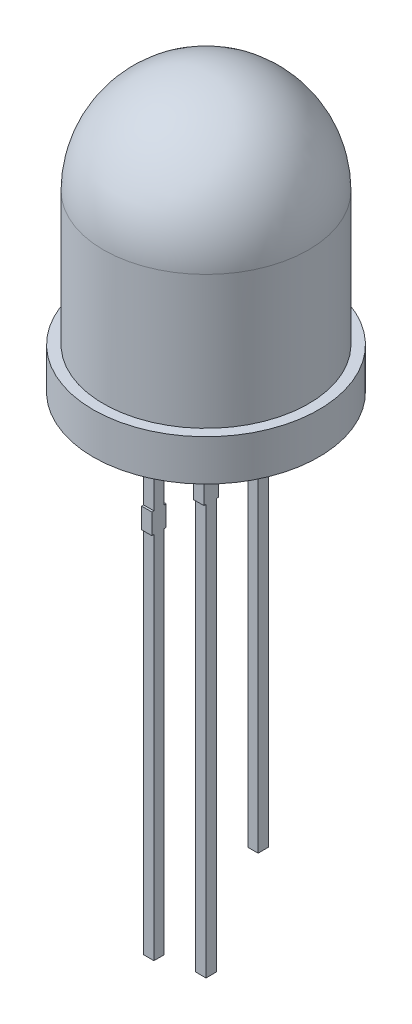
from build123d import *

# Parameters (mm, degrees)
SKETCH2_R          = 5.5
EXTRUDE1_DEPTH     = 2
SKETCH3_W          = 0.5
SKETCH3_H          = 16
SKETCH3_H_2        = 1
SKETCH3_W_2        = 0.1
SKETCH3_H_3        = 24.5
SKETCH3_W_3        = 0.7
EXTRUDE2_DEPTH     = 0.25
SKETCH4_W          = 0.026582279
SKETCH4_H          = 0.025316456
CUT_EXTRUDE1_DEPTH = 0.01


with BuildPart() as part:
    # Sketch1 → Revolve1 (revolve)
    with BuildSketch(Plane.XY):
        with BuildLine():
            ThreePointArc((0, 11.5), (3.535533906, 10.035533906), (5, 6.5))
            Line((5, 6.5), (5, 0))
            Line((5, 0), (0, 0))
            Line((0, 0), (0, 11.5))
        make_face()
    revolve(axis=Axis((0, 0, 0), (0, 1, 0)))

    # Sketch2 → Extrude1 (add)
    with BuildSketch(Plane.XZ.offset(2)):
        with Locations(Location((0, 0, 0), (0, 0, 270))):  # turned: the seam where the file's is
            Circle(SKETCH2_R)
    extrude(amount=-EXTRUDE1_DEPTH)

    # Sketch3 → Extrude2 (add, symmetric)
    with BuildSketch(Plane(origin=(0, 0, 0), x_dir=(0, 0, -1), z_dir=(1, 0, 0))):
        with Locations((2.54, -14.5)):
            Rectangle(SKETCH3_W, SKETCH3_H)
        Polygon((2.79, -3.5), (1.992435853, -2), (1.492435853, -2), (2.29, -3.5), (2.29, -5.5), (2.79, -5.5), align=None)
        with Locations((2.54, -6)):
            Rectangle(SKETCH3_W, SKETCH3_H_2)
        with Locations((2.24, -6)):
            Rectangle(SKETCH3_W_2, SKETCH3_H_2)
        with Locations((2.84, -6)):
            Rectangle(SKETCH3_W_2, SKETCH3_H_2)
        with Locations((0, -14.25)):
            Rectangle(SKETCH3_W, SKETCH3_H_3)
        with Locations((0, -6)):
            Rectangle(SKETCH3_W_3, SKETCH3_H_2)
        with Locations((-2.54, -6)):
            Rectangle(SKETCH3_W_3, SKETCH3_H_2)
        Polygon((-2.29, -24.5), (-2.29, -3.5), (-1.29, -3.5), (-1.29, -2), (-1.79, -2), (-1.79, -3), (-2.79, -3), (-2.79, -24.5), align=None)
    extrude(amount=EXTRUDE2_DEPTH, both=True)

    # Sketch4 → Cut-Extrude1 (cut)
    with BuildSketch(Plane.XZ.offset(2)):
        Polygon((-3.369199885, 0.572151899), (-3.44388343, 0.595609177), (-3.44388343, 0.620352057), (-3.393547196, 0.636768196), (-3.44388343, 0.652294304), (-3.44388343, 0.678026108), (-3.369199885, 0.701265823), (-3.369199885, 0.676087816), (-3.420683272, 0.663093354), (-3.369199885, 0.646677215), (-3.369199885, 0.625178006), (-3.420683272, 0.608860759), (-3.369199885, 0.596044304), align=None)
        Polygon((-3.369199885, 0.437974684), (-3.44388343, 0.461431962), (-3.44388343, 0.486174842), (-3.393547196, 0.502590981), (-3.44388343, 0.518117089), (-3.44388343, 0.543848892), (-3.369199885, 0.567088608), (-3.369199885, 0.541910601), (-3.420683272, 0.528916139), (-3.369199885, 0.5125), (-3.369199885, 0.491000791), (-3.420683272, 0.474683544), (-3.369199885, 0.461867089), align=None)
        Polygon((-3.369199885, 0.303797468), (-3.44388343, 0.327254747), (-3.44388343, 0.351997627), (-3.393547196, 0.368413766), (-3.44388343, 0.383939873), (-3.44388343, 0.409671677), (-3.369199885, 0.432911392), (-3.369199885, 0.407733386), (-3.420683272, 0.394738924), (-3.369199885, 0.378322785), (-3.369199885, 0.356823576), (-3.420683272, 0.340506329), (-3.369199885, 0.327689873), align=None)
        with Locations((-3.43059229, 0.275949367)):
            Rectangle(SKETCH4_W, SKETCH4_H)
        with BuildLine():
            add(Edge.make_bspline(
                [(-3.412712544, 0.159493671), (-3.413934677, 0.159530169), (-3.41633454, 0.15960184), (-3.419842228, 0.160211426), (-3.423166531, 0.161205393), (-3.426330677, 0.162577732), (-3.429300166, 0.164371189), (-3.432103057, 0.16655446), (-3.434707602, 0.169143343), (-3.437143976, 0.172090146), (-3.439326088, 0.175387089), (-3.441232121, 0.178984804), (-3.442826792, 0.18286483), (-3.444165857, 0.187013042), (-3.445154291, 0.191459588), (-3.445878278, 0.196177087), (-3.446351596, 0.201170514), (-3.446393564, 0.204594091), (-3.446415075, 0.206348892)],
                knots=[0, 0, 0, 0, 0.907312236, 1.78165839, 2.635367075, 3.479697475, 4.336364812, 5.205276731, 6.11257575, 7.058770404, 8.040786331, 9.044147278, 10.078219212, 11.153049307, 12.278104542, 13.457648573, 14.696882856, 16, 16, 16, 16], degree=3))
            add(Edge.make_bspline(
                [(-3.446415075, 0.206348892), (-3.446391004, 0.208367148), (-3.446344379, 0.21227633), (-3.44591578, 0.217939855), (-3.44526964, 0.223207892), (-3.444303099, 0.228103607), (-3.443102333, 0.232708206), (-3.441811042, 0.237141474), (-3.440346626, 0.241422786), (-3.439246468, 0.244195876), (-3.438701468, 0.24556962)],
                knots=[0, 0, 0, 0, 1.203215828, 2.33052265, 3.384689099, 4.366106119, 5.303329643, 6.221311756, 7.118865988, 8, 8, 8, 8], degree=3))
            Line((-3.438701468, 0.24556962), (-3.414769506, 0.24556962))
            Line((-3.414769506, 0.24556962), (-3.414769506, 0.242721519))
            add(Edge.make_bspline(
                [(-3.414769506, 0.242721519), (-3.415850961, 0.241356205), (-3.418007522, 0.238633592), (-3.420770127, 0.234200359), (-3.42317229, 0.229552713), (-3.425146291, 0.224707243), (-3.426732616, 0.219810398), (-3.427826143, 0.21493502), (-3.428573492, 0.210169433), (-3.428653998, 0.207010864), (-3.428693556, 0.205458861)],
                knots=[0, 0, 0, 0, 1.030622468, 2.055194264, 3.087043286, 4.125157485, 5.149848264, 6.130935704, 7.081611712, 8, 8, 8, 8], degree=3))
            add(Edge.make_bspline(
                [(-3.428693556, 0.205458861), (-3.428692662, 0.205030082), (-3.428690747, 0.2041121), (-3.428561904, 0.202644063), (-3.42846874, 0.200985464), (-3.428259523, 0.199206598), (-3.42804094, 0.197415781), (-3.427660619, 0.195761121), (-3.427298781, 0.194257482), (-3.426930603, 0.193351), (-3.426755265, 0.192919304)],
                knots=[0, 0, 0, 0, 0.806378557, 1.726393851, 2.771014456, 3.931269413, 5.096090628, 6.161710732, 7.124547685, 8, 8, 8, 8], degree=3))
            add(Edge.make_bspline(
                [(-3.426755265, 0.192919304), (-3.426527441, 0.192439517), (-3.426079719, 0.191496634), (-3.425262113, 0.190201714), (-3.424390811, 0.189019042), (-3.423425392, 0.187957582), (-3.422247483, 0.187107314), (-3.420846627, 0.186479113), (-3.419196327, 0.186136019), (-3.418021316, 0.186096725), (-3.417400044, 0.186075949)],
                knots=[0, 0, 0, 0, 1.024407818, 2.013179384, 2.949802342, 3.859052226, 4.77034807, 5.732977883, 6.801339628, 8, 8, 8, 8], degree=3))
            add(Edge.make_bspline(
                [(-3.417400044, 0.186075949), (-3.416854148, 0.186107391), (-3.415780755, 0.186169215), (-3.414252759, 0.186751006), (-3.412830882, 0.187633905), (-3.411570167, 0.188920927), (-3.410412728, 0.190515003), (-3.409442431, 0.19247074), (-3.408562358, 0.194723719), (-3.408145089, 0.196368178), (-3.407926151, 0.197231013)],
                knots=[0, 0, 0, 0, 0.825212765, 1.622611382, 2.449701629, 3.348069183, 4.336544339, 5.428209675, 6.6506027, 8, 8, 8, 8], degree=3))
            add(Edge.make_bspline(
                [(-3.407926151, 0.197231013), (-3.407478411, 0.19919974), (-3.406561221, 0.203232648), (-3.405414114, 0.209380757), (-3.404148041, 0.215510984), (-3.4029385, 0.219469696), (-3.40234862, 0.221400316)],
                knots=[0, 0, 0, 0, 0.976104583, 1.999535498, 3.024395274, 4, 4, 4, 4], degree=3))
            add(Edge.make_bspline(
                [(-3.40234862, 0.221400316), (-3.401995627, 0.222438832), (-3.401308494, 0.224460401), (-3.400146869, 0.227351945), (-3.398876917, 0.230013057), (-3.397521785, 0.232453168), (-3.396047787, 0.23465249), (-3.394514398, 0.236647679), (-3.392860561, 0.238391205), (-3.391128641, 0.239938889), (-3.389276638, 0.241262203), (-3.387332502, 0.242416954), (-3.385272036, 0.243392589), (-3.383110748, 0.244201473), (-3.380831879, 0.244818545), (-3.378455006, 0.245239801), (-3.375971646, 0.24553819), (-3.374277292, 0.245559001), (-3.373412702, 0.24556962)],
                knots=[0, 0, 0, 0, 1.287286806, 2.505824366, 3.654938963, 4.74627059, 5.778586806, 6.75996495, 7.696030012, 8.595059759, 9.482019644, 10.363222407, 11.245851011, 12.154256429, 13.068444161, 14.012503255, 14.985824751, 16, 16, 16, 16], degree=3))
            add(Edge.make_bspline(
                [(-3.373412702, 0.24556962), (-3.372256557, 0.245532318), (-3.369981285, 0.245458909), (-3.366652241, 0.24485748), (-3.363503504, 0.24383089), (-3.360500041, 0.242444827), (-3.357686955, 0.240616199), (-3.355008407, 0.238431404), (-3.352536816, 0.235807357), (-3.350236482, 0.232830235), (-3.348157084, 0.229542851), (-3.346326527, 0.226003867), (-3.344789876, 0.222234578), (-3.343515982, 0.218249032), (-3.342561311, 0.214030563), (-3.341842379, 0.20959333), (-3.341429198, 0.204919541), (-3.341377947, 0.20172812), (-3.341351784, 0.200098892)],
                knots=[0, 0, 0, 0, 0.894990994, 1.761326291, 2.609044902, 3.454222546, 4.315366365, 5.200560057, 6.125081389, 7.100429509, 8.110379559, 9.133447974, 10.182136699, 11.259192205, 12.370181258, 13.528580438, 14.738335141, 16, 16, 16, 16], degree=3))
            add(Edge.make_bspline(
                [(-3.341351784, 0.200098892), (-3.341373976, 0.198430205), (-3.341418321, 0.19509566), (-3.341796299, 0.190114218), (-3.342351527, 0.185153716), (-3.343193232, 0.180289886), (-3.344169649, 0.175599331), (-3.345265445, 0.171186095), (-3.346503409, 0.167106634), (-3.347457754, 0.16453297), (-3.34791824, 0.163291139)],
                knots=[0, 0, 0, 0, 1.065403572, 2.129000689, 3.188532477, 4.251604565, 5.279552602, 6.247508681, 7.154397237, 8, 8, 8, 8], degree=3))
            Line((-3.34791824, 0.163291139), (-3.370465708, 0.163291139))
            Line((-3.370465708, 0.163291139), (-3.370465708, 0.166119462))
            add(Edge.make_bspline(
                [(-3.370465708, 0.166119462), (-3.369665362, 0.167192367), (-3.368028632, 0.169386485), (-3.365944959, 0.173046122), (-3.363987094, 0.177004358), (-3.362302935, 0.181283188), (-3.360843454, 0.185742216), (-3.359824288, 0.190325174), (-3.359182478, 0.194951338), (-3.359109703, 0.198053049), (-3.359073303, 0.19960443)],
                knots=[0, 0, 0, 0, 0.892283326, 1.824742884, 2.804416662, 3.836872171, 4.8899239, 5.931447339, 6.965372909, 8, 8, 8, 8], degree=3))
            add(Edge.make_bspline(
                [(-3.359073303, 0.19960443), (-3.359094755, 0.200700098), (-3.359137658, 0.202891315), (-3.359528342, 0.206159523), (-3.360159236, 0.209401584), (-3.360978517, 0.211442107), (-3.361387385, 0.212460443)],
                knots=[0, 0, 0, 0, 0.999146175, 1.998183711, 3.000980573, 4, 4, 4, 4], degree=3))
            add(Edge.make_bspline(
                [(-3.361387385, 0.212460443), (-3.361588852, 0.212893946), (-3.361991651, 0.213760664), (-3.362764215, 0.214967308), (-3.363693026, 0.216071977), (-3.364745019, 0.217064055), (-3.365901392, 0.217932452), (-3.367176218, 0.218547803), (-3.368539133, 0.218923676), (-3.369474364, 0.218965835), (-3.369951468, 0.218987342)],
                knots=[0, 0, 0, 0, 1.00524851, 2.009826503, 3.004679593, 4.035271301, 5.048246368, 6.034938417, 6.997532266, 8, 8, 8, 8], degree=3))
            add(Edge.make_bspline(
                [(-3.369951468, 0.218987342), (-3.370589633, 0.218952904), (-3.371809109, 0.218887095), (-3.373524905, 0.218280511), (-3.375003339, 0.217295678), (-3.375998259, 0.216135073), (-3.376695697, 0.215017943), (-3.377206207, 0.213982284), (-3.377689566, 0.212773057), (-3.378187034, 0.211401809), (-3.378678222, 0.209865482), (-3.379153769, 0.208156925), (-3.379603064, 0.206274208), (-3.379889255, 0.204958333), (-3.380038493, 0.204272152)],
                knots=[0, 0, 0, 0, 1.173816843, 2.243057204, 3.312297565, 4.415174738, 5.03266065, 5.73970059, 6.541434878, 7.433956553, 8.430083051, 9.515931566, 10.70464786, 12, 12, 12, 12], degree=3))
            add(Edge.make_bspline(
                [(-3.380038493, 0.204272152), (-3.380414555, 0.202439363), (-3.381153432, 0.198838337), (-3.382256921, 0.193437153), (-3.38353189, 0.18793438), (-3.384680693, 0.184269053), (-3.38527979, 0.182357595)],
                knots=[0, 0, 0, 0, 0.995744513, 1.956417928, 2.934277412, 4, 4, 4, 4], degree=3))
            add(Edge.make_bspline(
                [(-3.38527979, 0.182357595), (-3.385599034, 0.181411041), (-3.386223527, 0.179559428), (-3.38730981, 0.176918797), (-3.388483792, 0.174471738), (-3.389725324, 0.172204706), (-3.39106929, 0.170130736), (-3.392491937, 0.168236053), (-3.394018846, 0.166552235), (-3.395632073, 0.16505467), (-3.397342174, 0.16373551), (-3.399181246, 0.162603212), (-3.401130049, 0.161630984), (-3.403216249, 0.160861379), (-3.405410836, 0.160243358), (-3.407742203, 0.159820261), (-3.41018658, 0.159526278), (-3.411861157, 0.159504661), (-3.412712544, 0.159493671)],
                knots=[0, 0, 0, 0, 1.237467875, 2.420686895, 3.535046182, 4.599015201, 5.620884487, 6.594603852, 7.531477383, 8.433220087, 9.318759595, 10.202828513, 11.105163009, 12.01247538, 12.953896178, 13.926381251, 14.945733412, 16, 16, 16, 16], degree=3))
        make_face()
        with BuildLine():
            Line((-3.44388343, 0.067088608), (-3.44388343, 0.091139241))
            Line((-3.44388343, 0.091139241), (-3.436051151, 0.091139241))
            add(Edge.make_bspline(
                [(-3.436051151, 0.091139241), (-3.43685971, 0.092232549), (-3.438418598, 0.094340433), (-3.440498816, 0.097513458), (-3.442274082, 0.100539548), (-3.443833302, 0.103453039), (-3.445008688, 0.106475242), (-3.445836754, 0.109706756), (-3.446336527, 0.113209581), (-3.446388311, 0.115636475), (-3.446415075, 0.116890823)],
                knots=[0, 0, 0, 0, 1.150872466, 2.218865267, 3.209461834, 4.120482262, 5.012764827, 5.946708227, 6.938749913, 8, 8, 8, 8], degree=3))
            add(Edge.make_bspline(
                [(-3.446415075, 0.116890823), (-3.446392356, 0.117907175), (-3.446348116, 0.119886305), (-3.446003238, 0.122763545), (-3.445465587, 0.125471173), (-3.444657996, 0.127986213), (-3.443692193, 0.130350202), (-3.442412235, 0.132487752), (-3.44098206, 0.134491354), (-3.439275015, 0.136273026), (-3.437377282, 0.137888648), (-3.435244821, 0.139271198), (-3.432911896, 0.140448909), (-3.430360042, 0.141390006), (-3.427601739, 0.142145096), (-3.424622491, 0.142669028), (-3.421435363, 0.142989621), (-3.419240233, 0.14302156), (-3.418112069, 0.143037975)],
                knots=[0, 0, 0, 0, 1.109008058, 2.159558935, 3.158726032, 4.116861086, 5.039058877, 5.938775559, 6.82970133, 7.720510853, 8.624361809, 9.544451588, 10.487360536, 11.471068125, 12.508000841, 13.604731202, 14.768976642, 16, 16, 16, 16], degree=3))
            Line((-3.418112069, 0.143037975), (-3.369199885, 0.143037975))
            Line((-3.369199885, 0.143037975), (-3.369199885, 0.118987342))
            Line((-3.369199885, 0.118987342), (-3.406778999, 0.118987342))
            add(Edge.make_bspline(
                [(-3.406778999, 0.118987342), (-3.40769547, 0.118985706), (-3.409449686, 0.118982576), (-3.411955492, 0.118900237), (-3.414223665, 0.118779336), (-3.416265694, 0.118640631), (-3.418112444, 0.118387615), (-3.419778606, 0.118009906), (-3.421298207, 0.11753908), (-3.422204909, 0.117074761), (-3.422641341, 0.116851266)],
                knots=[0, 0, 0, 0, 1.361401701, 2.605856924, 3.723918663, 4.735739235, 5.645738665, 6.489217889, 7.27279937, 8, 8, 8, 8], degree=3))
            add(Edge.make_bspline(
                [(-3.422641341, 0.116851266), (-3.423040056, 0.116621259), (-3.423823895, 0.116169086), (-3.424830074, 0.115248796), (-3.425674341, 0.114170053), (-3.42633037, 0.112892449), (-3.426829318, 0.111405901), (-3.427169555, 0.109677971), (-3.427385057, 0.107692609), (-3.427412965, 0.106283591), (-3.427427734, 0.105537975)],
                knots=[0, 0, 0, 0, 0.849138082, 1.669332372, 2.503455908, 3.370611167, 4.311442699, 5.394692208, 6.621337967, 8, 8, 8, 8], degree=3))
            add(Edge.make_bspline(
                [(-3.427427734, 0.105537975), (-3.427410376, 0.104996691), (-3.427374689, 0.103883773), (-3.427142243, 0.102172461), (-3.426785568, 0.100375884), (-3.426125713, 0.097861301), (-3.424939534, 0.094694674), (-3.423585126, 0.092335372), (-3.422898461, 0.091139241)],
                knots=[0, 0, 0, 0, 0.638127216, 1.312033637, 2.033062677, 2.79661882, 4.375931797, 6, 6, 6, 6], degree=3))
            Line((-3.422898461, 0.091139241), (-3.369199885, 0.091139241))
            Line((-3.369199885, 0.091139241), (-3.369199885, 0.067088608))
            Line((-3.369199885, 0.067088608), (-3.44388343, 0.067088608))
        make_face()
        with BuildLine():
            Line((-3.44388343, -0.030379747), (-3.44388343, -0.006329114))
            Line((-3.44388343, -0.006329114), (-3.406304316, -0.006329114))
            add(Edge.make_bspline(
                [(-3.406304316, -0.006329114), (-3.404774273, -0.0063046), (-3.401723248, -0.006255716), (-3.397960837, -0.005973592), (-3.395118513, -0.00559507), (-3.393280632, -0.005225415), (-3.391732492, -0.004793715), (-3.390846733, -0.004381435), (-3.390441974, -0.004193038)],
                knots=[0, 0, 0, 0, 1.709124929, 3.408128882, 4.211124727, 4.91016634, 5.501986363, 6, 6, 6, 6], degree=3))
            add(Edge.make_bspline(
                [(-3.390441974, -0.004193038), (-3.390043921, -0.003948575), (-3.389263481, -0.003469272), (-3.388250468, -0.002531948), (-3.387421627, -0.001438061), (-3.386740076, -0.000167292), (-3.386269496, 0.001323905), (-3.385876266, 0.003040645), (-3.385709357, 0.005027263), (-3.385674197, 0.006434533), (-3.385655582, 0.007179589)],
                knots=[0, 0, 0, 0, 0.86006424, 1.686277094, 2.52783008, 3.38194165, 4.331801563, 5.402842185, 6.624978739, 8, 8, 8, 8], degree=3))
            add(Edge.make_bspline(
                [(-3.385655582, 0.007179589), (-3.385712319, 0.00831141), (-3.385828172, 0.010622505), (-3.38653968, 0.013484698), (-3.387358639, 0.015815302), (-3.38811747, 0.017667827), (-3.389088911, 0.019576457), (-3.389810734, 0.020855869), (-3.390184854, 0.021518987)],
                knots=[0, 0, 0, 0, 1.338371478, 2.732853438, 3.468019217, 4.261884641, 5.099136535, 6, 6, 6, 6], degree=3))
            Line((-3.390184854, 0.021518987), (-3.44388343, 0.021518987))
            Line((-3.44388343, 0.021518987), (-3.44388343, 0.04556962))
            Line((-3.44388343, 0.04556962), (-3.369199885, 0.04556962))
            Line((-3.369199885, 0.04556962), (-3.369199885, 0.021518987))
            Line((-3.369199885, 0.021518987), (-3.377032164, 0.021518987))
            add(Edge.make_bspline(
                [(-3.377032164, 0.021518987), (-3.376226012, 0.020461581), (-3.37465679, 0.018403276), (-3.37261637, 0.015224038), (-3.3708176, 0.01214014), (-3.369304784, 0.009087131), (-3.368098009, 0.005972176), (-3.36728702, 0.002709417), (-3.366743217, -0.000706989), (-3.366693523, -0.003043704), (-3.36666824, -0.004232595)],
                knots=[0, 0, 0, 0, 1.126119141, 2.192057864, 3.198061997, 4.149848529, 5.076251285, 6.021887753, 6.99356175, 8, 8, 8, 8], degree=3))
            add(Edge.make_bspline(
                [(-3.36666824, -0.004232595), (-3.366693629, -0.005228866), (-3.366743193, -0.007173765), (-3.367052902, -0.010008526), (-3.367603567, -0.012679947), (-3.368401396, -0.015172221), (-3.369387008, -0.017514841), (-3.370618523, -0.019676785), (-3.372076946, -0.021668856), (-3.373737949, -0.023497257), (-3.375627675, -0.025128075), (-3.377744939, -0.026545111), (-3.380088036, -0.027725092), (-3.382648345, -0.028695805), (-3.385413454, -0.029470228), (-3.388409419, -0.029985359), (-3.391613598, -0.030339143), (-3.393829641, -0.030365941), (-3.394971246, -0.030379747)],
                knots=[0, 0, 0, 0, 1.08848837, 2.124922927, 3.110950502, 4.063144162, 4.979605775, 5.882838355, 6.774625441, 7.671951181, 8.57587277, 9.494821853, 10.448322275, 11.435533005, 12.482327682, 13.580118324, 14.753386918, 16, 16, 16, 16], degree=3))
            Line((-3.394971246, -0.030379747), (-3.44388343, -0.030379747))
        make_face()
        Polygon((-3.44388343, -0.125316456), (-3.44388343, -0.053164557), (-3.34388343, -0.053164557), (-3.34388343, -0.078481013), (-3.424896088, -0.078481013), (-3.424896088, -0.125316456), align=None)
        Polygon((-3.44388343, -0.212658228), (-3.44388343, -0.140506329), (-3.34388343, -0.140506329), (-3.34388343, -0.212658228), (-3.362870772, -0.212658228), (-3.362870772, -0.165822785), (-3.38059229, -0.165822785), (-3.38059229, -0.208860759), (-3.399579632, -0.208860759), (-3.399579632, -0.165822785), (-3.424896088, -0.165822785), (-3.424896088, -0.212658228), align=None)
        with BuildLine():
            add(Edge.make_bspline(
                [(-3.393982322, -0.329113924), (-3.395130011, -0.329094609), (-3.397402897, -0.329056357), (-3.400767704, -0.328761165), (-3.404033379, -0.32823514), (-3.407217628, -0.327555959), (-3.410296555, -0.326633453), (-3.413304132, -0.325551739), (-3.416209626, -0.324242093), (-3.41901106, -0.322737241), (-3.421683163, -0.321087768), (-3.424203372, -0.319313019), (-3.42658659, -0.31746724), (-3.428781484, -0.315477927), (-3.430823503, -0.313398746), (-3.432714318, -0.311223217), (-3.434417748, -0.308918153), (-3.435440633, -0.30731099), (-3.435952259, -0.30650712)],
                knots=[0, 0, 0, 0, 1.105570398, 2.18947457, 3.250358341, 4.290584537, 5.323553275, 6.344225964, 7.367641686, 8.3905646, 9.405808457, 10.390761353, 11.358902336, 12.307789878, 13.241960776, 14.165076779, 15.082208636, 16, 16, 16, 16], degree=3))
            add(Edge.make_bspline(
                [(-3.435952259, -0.30650712), (-3.436664398, -0.305267892), (-3.438092311, -0.302783112), (-3.439760901, -0.298799278), (-3.441165017, -0.294673795), (-3.442219442, -0.290323409), (-3.442946486, -0.285676399), (-3.443507292, -0.28067499), (-3.443809052, -0.275267401), (-3.443858072, -0.271532506), (-3.44388343, -0.269600475)],
                knots=[0, 0, 0, 0, 0.896288622, 1.797150563, 2.705281913, 3.629615989, 4.602417572, 5.655716007, 6.787320449, 8, 8, 8, 8], degree=3))
            Line((-3.44388343, -0.269600475), (-3.44388343, -0.234177215))
            Line((-3.44388343, -0.234177215), (-3.34388343, -0.234177215))
            Line((-3.34388343, -0.234177215), (-3.34388343, -0.270609177))
            add(Edge.make_bspline(
                [(-3.34388343, -0.270609177), (-3.343900041, -0.272587909), (-3.343932081, -0.276404637), (-3.344349672, -0.281921476), (-3.344946496, -0.287026684), (-3.345871367, -0.291712032), (-3.346986712, -0.296012037), (-3.34834584, -0.299937513), (-3.349844548, -0.303549287), (-3.351118241, -0.305728129), (-3.351735487, -0.306784019)],
                knots=[0, 0, 0, 0, 1.267175336, 2.444223962, 3.542125549, 4.557526608, 5.500936977, 6.385043188, 7.217374394, 8, 8, 8, 8], degree=3))
            add(Edge.make_bspline(
                [(-3.351735487, -0.306784019), (-3.352272027, -0.307634972), (-3.353338941, -0.309327097), (-3.355120793, -0.311728312), (-3.35707687, -0.313957739), (-3.359128689, -0.316086242), (-3.361331576, -0.318066059), (-3.363670283, -0.319909259), (-3.366148377, -0.321613076), (-3.368757846, -0.323171039), (-3.371487898, -0.324591854), (-3.374360957, -0.32578116), (-3.377339487, -0.326830509), (-3.380448449, -0.327636046), (-3.383656286, -0.32833396), (-3.38699763, -0.328768694), (-3.390450118, -0.329055305), (-3.392795008, -0.32909422), (-3.393982322, -0.329113924)],
                knots=[0, 0, 0, 0, 0.964065863, 1.917049184, 2.86229036, 3.805247319, 4.749389377, 5.698846072, 6.657678277, 7.629829384, 8.610569287, 9.604676042, 10.607940105, 11.6349849, 12.681042988, 13.752616828, 14.862056989, 16, 16, 16, 16], degree=3))
        make_face()
        with BuildLine():
            add(Edge.make_bspline(
                [(-3.393824094, -0.302531646), (-3.393019334, -0.302521405), (-3.39144075, -0.302501317), (-3.389125236, -0.30230975), (-3.386895586, -0.302050694), (-3.384760894, -0.30161964), (-3.382701323, -0.301119993), (-3.380743829, -0.300477843), (-3.378864256, -0.299753447), (-3.377086767, -0.298871809), (-3.375378385, -0.297898172), (-3.373792869, -0.296750679), (-3.372279983, -0.295502341), (-3.370851999, -0.294124054), (-3.369546103, -0.292581114), (-3.368316026, -0.290921012), (-3.3671877, -0.289120654), (-3.366527651, -0.287847665), (-3.366193556, -0.287203323)],
                knots=[0, 0, 0, 0, 1.152093354, 2.259898929, 3.325467225, 4.364140538, 5.376172865, 6.358396836, 7.312077728, 8.257828931, 9.196960457, 10.124297759, 11.056236784, 12.004246951, 12.961658638, 13.947279359, 14.960983522, 16, 16, 16, 16], degree=3))
            add(Edge.make_bspline(
                [(-3.366193556, -0.287203323), (-3.365886844, -0.286528425), (-3.36527892, -0.285190731), (-3.364547727, -0.283119908), (-3.363974892, -0.281030524), (-3.363544033, -0.278828925), (-3.363222103, -0.276359165), (-3.363024844, -0.273433583), (-3.362882675, -0.269977674), (-3.362874923, -0.267490959), (-3.362870772, -0.266159019)],
                knots=[0, 0, 0, 0, 0.826967603, 1.639107464, 2.447640171, 3.242670507, 4.14065217, 5.225198036, 6.513753944, 8, 8, 8, 8], degree=3))
            Line((-3.362870772, -0.266159019), (-3.362870772, -0.259493671))
            Line((-3.362870772, -0.259493671), (-3.424896088, -0.259493671))
            Line((-3.424896088, -0.259493671), (-3.424896088, -0.266159019))
            add(Edge.make_bspline(
                [(-3.424896088, -0.266159019), (-3.424891338, -0.266917226), (-3.424882169, -0.268380991), (-3.424839107, -0.270497235), (-3.424792219, -0.272463031), (-3.424675757, -0.274267902), (-3.424603111, -0.275926587), (-3.424424732, -0.277413368), (-3.424282552, -0.278755857), (-3.424014829, -0.280323454), (-3.423598646, -0.28217662), (-3.422920467, -0.28433788), (-3.422070072, -0.286478414), (-3.421385104, -0.287866987), (-3.421039284, -0.288568038)],
                knots=[0, 0, 0, 0, 1.186793418, 2.291178421, 3.313283093, 4.264083014, 5.122158624, 5.910777728, 6.607099052, 7.234812932, 8.398911528, 9.577194775, 10.776795607, 12, 12, 12, 12], degree=3))
            add(Edge.make_bspline(
                [(-3.421039284, -0.288568038), (-3.420697768, -0.289153154), (-3.420024253, -0.29030708), (-3.41889018, -0.291930584), (-3.417682455, -0.293438302), (-3.416394004, -0.294834314), (-3.415005762, -0.296097614), (-3.413539221, -0.297249633), (-3.411991242, -0.298280082), (-3.409797725, -0.299515471), (-3.406766788, -0.300738716), (-3.402799402, -0.301778259), (-3.398439639, -0.30241513), (-3.395402021, -0.302491812), (-3.393824094, -0.302531646)],
                knots=[0, 0, 0, 0, 0.755160452, 1.489275589, 2.205657296, 2.907868421, 3.605098304, 4.296256403, 4.985378686, 5.676536785, 7.100390329, 8.614249252, 10.241231541, 12, 12, 12, 12], degree=3))
        make_face(mode=Mode.SUBTRACT)
        with Locations((-3.43059229, -0.360759494)):
            Rectangle(SKETCH4_W, SKETCH4_H)
        with BuildLine():
            add(Edge.make_bspline(
                [(-3.446415075, -0.435403481), (-3.446393264, -0.433813368), (-3.446350452, -0.430692232), (-3.445873535, -0.42612089), (-3.44515584, -0.421755717), (-3.444134934, -0.417609409), (-3.442787437, -0.413695618), (-3.441134502, -0.41003198), (-3.439149317, -0.406625123), (-3.437570109, -0.404566476), (-3.436782955, -0.403540348)],
                knots=[0, 0, 0, 0, 1.123670284, 2.205584497, 3.245308791, 4.249063313, 5.220352711, 6.167273909, 7.086481357, 8, 8, 8, 8], degree=3))
            add(Edge.make_bspline(
                [(-3.436782955, -0.403540348), (-3.435928181, -0.402588601), (-3.434221938, -0.400688786), (-3.431250511, -0.398222853), (-3.427967467, -0.396099767), (-3.424365245, -0.394314215), (-3.420448516, -0.392883291), (-3.416203853, -0.391860157), (-3.411643073, -0.391240912), (-3.408495139, -0.391173746), (-3.406877892, -0.391139241)],
                knots=[0, 0, 0, 0, 0.916457077, 1.82937027, 2.759194969, 3.714948755, 4.706655623, 5.743329475, 6.840637961, 8, 8, 8, 8], degree=3))
            add(Edge.make_bspline(
                [(-3.406877892, -0.391139241), (-3.405174665, -0.391178001), (-3.401873585, -0.391253124), (-3.397101397, -0.391916883), (-3.392683716, -0.392986496), (-3.388631808, -0.394524054), (-3.384938617, -0.396454496), (-3.381566782, -0.398718989), (-3.378523858, -0.401339514), (-3.376778418, -0.403346653), (-3.37590479, -0.404351266)],
                knots=[0, 0, 0, 0, 1.171797512, 2.271099083, 3.308930235, 4.294129479, 5.24602549, 6.17106565, 7.084581485, 8, 8, 8, 8], degree=3))
            add(Edge.make_bspline(
                [(-3.37590479, -0.404351266), (-3.375136204, -0.405377136), (-3.373589748, -0.407441268), (-3.371689048, -0.410844773), (-3.370094263, -0.414467988), (-3.368846618, -0.418297559), (-3.367892712, -0.422270367), (-3.367168869, -0.426330027), (-3.366748311, -0.43047628), (-3.366695059, -0.43326648), (-3.36666824, -0.434671677)],
                knots=[0, 0, 0, 0, 0.952130878, 1.915761808, 2.890227217, 3.891541892, 4.905612075, 5.925811839, 6.955400088, 8, 8, 8, 8], degree=3))
            add(Edge.make_bspline(
                [(-3.36666824, -0.434671677), (-3.366685242, -0.435918396), (-3.366718674, -0.438369867), (-3.367040784, -0.441970914), (-3.367573903, -0.445425455), (-3.368312505, -0.448730387), (-3.369204108, -0.451904334), (-3.37024325, -0.454954511), (-3.371376518, -0.457914321), (-3.372261053, -0.45981489), (-3.372700677, -0.460759494)],
                knots=[0, 0, 0, 0, 1.107648782, 2.178012834, 3.209595929, 4.211695017, 5.185427128, 6.137685403, 7.07440854, 8, 8, 8, 8], degree=3))
            Line((-3.372700677, -0.460759494), (-3.393250518, -0.460759494))
            Line((-3.393250518, -0.460759494), (-3.393250518, -0.45741693))
            add(Edge.make_bspline(
                [(-3.393250518, -0.45741693), (-3.392833298, -0.456917386), (-3.391931584, -0.45583775), (-3.390510832, -0.454051335), (-3.388981238, -0.451902393), (-3.388089292, -0.450248857), (-3.387613651, -0.449367089)],
                knots=[0, 0, 0, 0, 0.792826818, 1.713491785, 2.780691913, 4, 4, 4, 4], degree=3))
            add(Edge.make_bspline(
                [(-3.387613651, -0.449367089), (-3.387171693, -0.448439154), (-3.386265833, -0.446537209), (-3.385433, -0.443981204), (-3.384865273, -0.441789202), (-3.384608852, -0.439971666), (-3.38441929, -0.438038046), (-3.384399784, -0.436702803), (-3.384389759, -0.436016614)],
                knots=[0, 0, 0, 0, 1.332524827, 2.731214173, 3.480270227, 4.267952375, 5.109889624, 6, 6, 6, 6], degree=3))
            add(Edge.make_bspline(
                [(-3.384389759, -0.436016614), (-3.384409308, -0.435251058), (-3.384447195, -0.433767448), (-3.38472425, -0.431605939), (-3.385202509, -0.429587528), (-3.385842609, -0.427684306), (-3.386730222, -0.425946243), (-3.387763859, -0.424319403), (-3.38898966, -0.422827143), (-3.390430603, -0.421507882), (-3.392010532, -0.420315156), (-3.393744647, -0.419295954), (-3.395591246, -0.418383498), (-3.397595695, -0.41768856), (-3.399724471, -0.417128822), (-3.401987591, -0.416739892), (-3.404387101, -0.416497934), (-3.406033409, -0.416470016), (-3.406877892, -0.416455696)],
                knots=[0, 0, 0, 0, 1.087302107, 2.107140881, 3.088415001, 4.030197574, 4.951552271, 5.852940509, 6.764198256, 7.685219758, 8.621679636, 9.570836121, 10.538340132, 11.542450476, 12.578202196, 13.66207107, 14.800746211, 16, 16, 16, 16], degree=3))
            add(Edge.make_bspline(
                [(-3.406877892, -0.416455696), (-3.407742048, -0.416470471), (-3.409421061, -0.416499177), (-3.411862672, -0.416732691), (-3.414144103, -0.417148582), (-3.416269423, -0.41771983), (-3.418235441, -0.418444178), (-3.420032838, -0.419349295), (-3.421689645, -0.420385652), (-3.423152257, -0.42163021), (-3.424468578, -0.422994093), (-3.425604713, -0.424508985), (-3.426552858, -0.426168224), (-3.427357321, -0.427950405), (-3.427935719, -0.429883445), (-3.428372411, -0.431939982), (-3.428660968, -0.434129537), (-3.42868253, -0.435639891), (-3.428693556, -0.436412184)],
                knots=[0, 0, 0, 0, 1.230336593, 2.390482092, 3.487897344, 4.52859895, 5.520747884, 6.465347575, 7.38981449, 8.296085817, 9.192433006, 10.084246191, 10.984321635, 11.908883871, 12.862027947, 13.850751296, 14.901019963, 16, 16, 16, 16], degree=3))
            add(Edge.make_bspline(
                [(-3.428693556, -0.436412184), (-3.428685429, -0.437138038), (-3.428669584, -0.438553063), (-3.428451508, -0.44061781), (-3.428175625, -0.442578718), (-3.427736217, -0.444414258), (-3.427193842, -0.446109524), (-3.426627336, -0.447669947), (-3.426022551, -0.449082395), (-3.425554997, -0.449943749), (-3.425331215, -0.450356013)],
                knots=[0, 0, 0, 0, 1.200823684, 2.340960236, 3.433630075, 4.476504061, 5.46014544, 6.378484521, 7.223905657, 8, 8, 8, 8], degree=3))
            add(Edge.make_bspline(
                [(-3.425331215, -0.450356013), (-3.42490132, -0.451056218), (-3.424069678, -0.452410785), (-3.422668112, -0.454249513), (-3.421253852, -0.455894382), (-3.420297635, -0.456918894), (-3.419832797, -0.45741693)],
                knots=[0, 0, 0, 0, 1.098601379, 2.125273733, 3.088655601, 4, 4, 4, 4], degree=3))
            Line((-3.419832797, -0.45741693), (-3.419832797, -0.460759494))
            Line((-3.419832797, -0.460759494), (-3.440540866, -0.460759494))
            add(Edge.make_bspline(
                [(-3.440540866, -0.460759494), (-3.440978361, -0.459814104), (-3.441853454, -0.457923097), (-3.443007326, -0.455008518), (-3.443975486, -0.452020545), (-3.444878567, -0.448972172), (-3.445566929, -0.445800089), (-3.446060052, -0.442477058), (-3.446360964, -0.43899556), (-3.446396792, -0.436617171), (-3.446415075, -0.435403481)],
                knots=[0, 0, 0, 0, 0.952012952, 1.904254716, 2.862729541, 3.822037426, 4.808956931, 5.82647221, 6.890850784, 8, 8, 8, 8], degree=3))
        make_face()
        with BuildLine():
            add(Edge.make_bspline(
                [(-3.406581215, -0.553164557), (-3.408086121, -0.553139862), (-3.411019586, -0.553091723), (-3.415291378, -0.552552407), (-3.419327375, -0.551739627), (-3.423114584, -0.550567096), (-3.426671858, -0.549086703), (-3.429961651, -0.547235764), (-3.433014881, -0.545064759), (-3.435804765, -0.542573722), (-3.438303276, -0.53977252), (-3.440498529, -0.536698338), (-3.442311971, -0.533324511), (-3.443824061, -0.5297102), (-3.444993296, -0.525825548), (-3.445806013, -0.521671329), (-3.446341484, -0.517254195), (-3.446390136, -0.514215776), (-3.446415075, -0.512658228)],
                knots=[0, 0, 0, 0, 1.120167703, 2.183507516, 3.201345984, 4.182878364, 5.131270247, 6.065524964, 6.98789854, 7.91635504, 8.84481154, 9.778033504, 10.722808862, 11.691211189, 12.691525459, 13.738229926, 14.840575679, 16, 16, 16, 16], degree=3))
            add(Edge.make_bspline(
                [(-3.446415075, -0.512658228), (-3.446390053, -0.511100707), (-3.446341241, -0.508062341), (-3.44580691, -0.503644832), (-3.444988959, -0.499485737), (-3.443832858, -0.49559643), (-3.442306309, -0.491987684), (-3.440499261, -0.488617817), (-3.438303067, -0.485544052), (-3.435804875, -0.482742566), (-3.433014649, -0.480252248), (-3.429962466, -0.478078657), (-3.426666512, -0.476236243), (-3.423123467, -0.474718389), (-3.419322629, -0.473585065), (-3.415292187, -0.472761602), (-3.411019367, -0.472225394), (-3.408086046, -0.472176819), (-3.406581215, -0.472151899)],
                knots=[0, 0, 0, 0, 1.15937715, 2.261678054, 3.308339936, 4.313313916, 5.277148057, 6.221884977, 7.155068972, 8.083487698, 9.011906424, 9.934242473, 10.868459181, 11.818729666, 12.798784262, 13.81658132, 14.879877871, 16, 16, 16, 16], degree=3))
            add(Edge.make_bspline(
                [(-3.406581215, -0.472151899), (-3.405069791, -0.472177022), (-3.40211678, -0.472226107), (-3.397817908, -0.472761477), (-3.393757257, -0.473579494), (-3.389948944, -0.474739526), (-3.386397344, -0.476255799), (-3.38309524, -0.478096824), (-3.380048665, -0.480293292), (-3.377258913, -0.48280279), (-3.374762532, -0.485614584), (-3.372589626, -0.488708516), (-3.370752969, -0.492060435), (-3.369231136, -0.495667634), (-3.368096571, -0.49955419), (-3.367278992, -0.503691132), (-3.36674092, -0.508088526), (-3.366692907, -0.511107264), (-3.36666824, -0.512658228)],
                knots=[0, 0, 0, 0, 1.124034801, 2.196132384, 3.217834281, 4.203147447, 5.152578239, 6.085969439, 7.010345409, 7.941219594, 8.872481455, 9.802010446, 10.748267785, 11.711250247, 12.709230373, 13.754967386, 14.846549946, 16, 16, 16, 16], degree=3))
            add(Edge.make_bspline(
                [(-3.36666824, -0.512658228), (-3.366692962, -0.514228966), (-3.366741094, -0.51728713), (-3.367277298, -0.521730542), (-3.368090302, -0.525904381), (-3.369256699, -0.529803006), (-3.370768112, -0.533428756), (-3.37260277, -0.536788831), (-3.374804828, -0.539860139), (-3.377311984, -0.542647393), (-3.380117385, -0.545127634), (-3.383167009, -0.54729655), (-3.386486725, -0.549103768), (-3.390041593, -0.550585538), (-3.393835362, -0.551757711), (-3.397869468, -0.552578696), (-3.402144465, -0.553084687), (-3.405076595, -0.553137471), (-3.406581215, -0.553164557)],
                knots=[0, 0, 0, 0, 1.167358552, 2.272800965, 3.322628764, 4.326027541, 5.29287265, 6.238482395, 7.166210353, 8.096447471, 9.020151799, 9.945039072, 10.873038967, 11.824425184, 12.804379233, 13.820580988, 14.881633558, 16, 16, 16, 16], degree=3))
        make_face()
        with BuildLine():
            add(Edge.make_bspline(
                [(-3.425074094, -0.523457278), (-3.424574088, -0.523812456), (-3.423556515, -0.524535285), (-3.421856092, -0.525405537), (-3.420034298, -0.526193542), (-3.418005016, -0.526811737), (-3.415702571, -0.527291059), (-3.413048978, -0.52760245), (-3.410013466, -0.527832094), (-3.407860753, -0.527842556), (-3.406719664, -0.527848101)],
                knots=[0, 0, 0, 0, 0.764956307, 1.556776596, 2.379454426, 3.241401993, 4.200532455, 5.312591107, 6.575484591, 8, 8, 8, 8], degree=3))
            add(Edge.make_bspline(
                [(-3.406719664, -0.527848101), (-3.405644782, -0.527830412), (-3.403585426, -0.527796522), (-3.400625663, -0.527610152), (-3.397942237, -0.527261478), (-3.39552484, -0.5267636), (-3.393354153, -0.526153829), (-3.39141179, -0.525427894), (-3.389693188, -0.524589376), (-3.388687956, -0.523903909), (-3.388207006, -0.523575949)],
                knots=[0, 0, 0, 0, 1.337076348, 2.561692668, 3.686680134, 4.69989255, 5.629188848, 6.488203485, 7.276684665, 8, 8, 8, 8], degree=3))
            add(Edge.make_bspline(
                [(-3.388207006, -0.523575949), (-3.387767723, -0.523238652), (-3.386905966, -0.522576962), (-3.385823782, -0.521400911), (-3.384925487, -0.520136352), (-3.384265447, -0.51875605), (-3.383746189, -0.517310883), (-3.383399353, -0.515802557), (-3.383171231, -0.514247405), (-3.383139853, -0.513193069), (-3.383123936, -0.512658228)],
                knots=[0, 0, 0, 0, 1.058684453, 2.076859345, 3.046867319, 4.017860406, 4.996047344, 5.981941452, 6.976284511, 8, 8, 8, 8], degree=3))
            add(Edge.make_bspline(
                [(-3.383123936, -0.512658228), (-3.383134882, -0.512130296), (-3.383156293, -0.511097679), (-3.383335975, -0.509595013), (-3.383630565, -0.508184065), (-3.384048498, -0.506844191), (-3.38464398, -0.505552217), (-3.385500405, -0.504317872), (-3.386575736, -0.503101936), (-3.387426254, -0.502363688), (-3.387870772, -0.501977848)],
                knots=[0, 0, 0, 0, 1.041978199, 2.038073998, 2.982578265, 3.884042198, 4.804014415, 5.778706634, 6.839057036, 8, 8, 8, 8], degree=3))
            add(Edge.make_bspline(
                [(-3.387870772, -0.501977848), (-3.388345398, -0.501644363), (-3.389343998, -0.500942719), (-3.391048518, -0.500059744), (-3.393010438, -0.49932839), (-3.39519418, -0.49863615), (-3.397665328, -0.498117886), (-3.400418606, -0.497717147), (-3.403473033, -0.497516433), (-3.40560525, -0.497484858), (-3.406719664, -0.497468354)],
                knots=[0, 0, 0, 0, 0.706185926, 1.485796665, 2.33004681, 3.254820698, 4.274138656, 5.402098861, 6.642194297, 8, 8, 8, 8], degree=3))
            add(Edge.make_bspline(
                [(-3.406719664, -0.497468354), (-3.407722128, -0.497477501), (-3.40966324, -0.497495212), (-3.412469625, -0.497694126), (-3.415073558, -0.498022802), (-3.41746359, -0.498499446), (-3.419648487, -0.49907369), (-3.421600146, -0.499821164), (-3.423355204, -0.500644638), (-3.424382945, -0.501344976), (-3.424876309, -0.501681171)],
                knots=[0, 0, 0, 0, 1.270915159, 2.460926195, 3.565223763, 4.596447547, 5.549594966, 6.425286377, 7.244063354, 8, 8, 8, 8], degree=3))
            add(Edge.make_bspline(
                [(-3.424876309, -0.501681171), (-3.425292795, -0.502021731), (-3.426113923, -0.502693168), (-3.427197939, -0.503842086), (-3.42805929, -0.505125798), (-3.428789778, -0.506477001), (-3.429319024, -0.507938804), (-3.42969563, -0.509490696), (-3.429911385, -0.511142431), (-3.429943112, -0.512275225), (-3.429959379, -0.512856013)],
                knots=[0, 0, 0, 0, 1.011121112, 1.993489184, 2.956264801, 3.910060304, 4.874908638, 5.87009835, 6.907993364, 8, 8, 8, 8], degree=3))
            add(Edge.make_bspline(
                [(-3.429959379, -0.512856013), (-3.429905797, -0.513856962), (-3.429798874, -0.515854325), (-3.429087223, -0.518269474), (-3.428237943, -0.520076797), (-3.427358688, -0.521316068), (-3.426319149, -0.522472259), (-3.425493172, -0.523125727), (-3.425074094, -0.523457278)],
                knots=[0, 0, 0, 0, 1.48399549, 2.96126462, 3.700919455, 4.439278468, 5.208134679, 6, 6, 6, 6], degree=3))
        make_face(mode=Mode.SUBTRACT)
        with BuildLine():
            Line((-3.390184854, -0.644303797), (-3.44388343, -0.644303797))
            Line((-3.44388343, -0.644303797), (-3.44388343, -0.620253165))
            Line((-3.44388343, -0.620253165), (-3.406027417, -0.620253165))
            add(Edge.make_bspline(
                [(-3.406027417, -0.620253165), (-3.405137383, -0.620247698), (-3.403429751, -0.62023721), (-3.400970137, -0.620204186), (-3.398721533, -0.620123915), (-3.396675334, -0.620016376), (-3.394815869, -0.619829431), (-3.393141033, -0.619518092), (-3.391635508, -0.619096595), (-3.39073456, -0.618688245), (-3.390303525, -0.61849288)],
                knots=[0, 0, 0, 0, 1.339742217, 2.570446543, 3.702449567, 4.726327994, 5.654556215, 6.512888379, 7.288529137, 8, 8, 8, 8], degree=3))
            add(Edge.make_bspline(
                [(-3.390303525, -0.61849288), (-3.389918158, -0.618282954), (-3.389154264, -0.61786683), (-3.388186403, -0.616998785), (-3.387375758, -0.615990476), (-3.386734304, -0.614810314), (-3.386236142, -0.613431631), (-3.385886796, -0.611816509), (-3.385706394, -0.609952652), (-3.385673157, -0.608630364), (-3.385655582, -0.607931171)],
                knots=[0, 0, 0, 0, 0.859345536, 1.703436662, 2.532498256, 3.390183975, 4.328249457, 5.402602062, 6.626559876, 8, 8, 8, 8], degree=3))
            add(Edge.make_bspline(
                [(-3.385655582, -0.607931171), (-3.385679144, -0.607343877), (-3.385726481, -0.60616399), (-3.38596802, -0.604405516), (-3.386469966, -0.602686303), (-3.387306604, -0.600467627), (-3.388523071, -0.597858323), (-3.38964496, -0.595885907), (-3.390184854, -0.594936709)],
                knots=[0, 0, 0, 0, 0.759443456, 1.525737455, 2.286422378, 3.068189154, 4.58910569, 6, 6, 6, 6], degree=3))
            Line((-3.390184854, -0.594936709), (-3.44388343, -0.594936709))
            Line((-3.44388343, -0.594936709), (-3.44388343, -0.570886076))
            Line((-3.44388343, -0.570886076), (-3.369199885, -0.570886076))
            Line((-3.369199885, -0.570886076), (-3.369199885, -0.594936709))
            Line((-3.369199885, -0.594936709), (-3.377032164, -0.594936709))
            add(Edge.make_bspline(
                [(-3.377032164, -0.594936709), (-3.376250682, -0.595957746), (-3.374733361, -0.597940187), (-3.372687425, -0.60095416), (-3.37092399, -0.603909643), (-3.369393432, -0.606810759), (-3.368138051, -0.609757207), (-3.367301285, -0.612851706), (-3.366768966, -0.616094453), (-3.366702224, -0.618312736), (-3.36666824, -0.619442247)],
                knots=[0, 0, 0, 0, 1.136140478, 2.205924536, 3.217129804, 4.176128364, 5.103417168, 6.04061054, 7.002313223, 8, 8, 8, 8], degree=3))
            add(Edge.make_bspline(
                [(-3.36666824, -0.619442247), (-3.366699985, -0.62064549), (-3.366762029, -0.622997145), (-3.367431291, -0.626409066), (-3.368435916, -0.629624954), (-3.369926349, -0.632580961), (-3.371759149, -0.635303105), (-3.374036857, -0.637694085), (-3.376682663, -0.639808625), (-3.378694298, -0.640898753), (-3.379722037, -0.641455696)],
                knots=[0, 0, 0, 0, 1.06605855, 2.083537511, 3.073064962, 4.046068917, 5.009676085, 5.97370914, 6.964773701, 8, 8, 8, 8], degree=3))
            add(Edge.make_bspline(
                [(-3.379722037, -0.641455696), (-3.378745078, -0.642637783), (-3.376841173, -0.644941441), (-3.374298477, -0.648495035), (-3.372044177, -0.651974192), (-3.370134463, -0.655414444), (-3.368589575, -0.658810095), (-3.367483975, -0.662189222), (-3.366800528, -0.665538003), (-3.366711827, -0.667771262), (-3.36666824, -0.668868671)],
                knots=[0, 0, 0, 0, 1.188124574, 2.315425566, 3.384037189, 4.39937427, 5.362203716, 6.270239573, 7.150007311, 8, 8, 8, 8], degree=3))
            add(Edge.make_bspline(
                [(-3.36666824, -0.668868671), (-3.366691614, -0.66985193), (-3.366737095, -0.671765088), (-3.367072392, -0.67454753), (-3.36764313, -0.677144118), (-3.368437382, -0.679566684), (-3.369460798, -0.681809925), (-3.370734628, -0.68386078), (-3.372240809, -0.685715362), (-3.373940614, -0.687408252), (-3.375874961, -0.688889581), (-3.378002622, -0.690193193), (-3.38035364, -0.69124157), (-3.382881755, -0.692146787), (-3.385619033, -0.692828576), (-3.388561631, -0.693319319), (-3.391701652, -0.693617336), (-3.393862988, -0.693652735), (-3.394971246, -0.693670886)],
                knots=[0, 0, 0, 0, 1.099321551, 2.138985818, 3.128101353, 4.067593225, 4.984602876, 5.878565082, 6.75932895, 7.650734189, 8.554641537, 9.477588118, 10.434248276, 11.427530835, 12.477080043, 13.583595796, 14.760951851, 16, 16, 16, 16], degree=3))
            Line((-3.394971246, -0.693670886), (-3.44388343, -0.693670886))
            Line((-3.44388343, -0.693670886), (-3.44388343, -0.669620253))
            Line((-3.44388343, -0.669620253), (-3.406027417, -0.669620253))
            add(Edge.make_bspline(
                [(-3.406027417, -0.669620253), (-3.405130801, -0.669614543), (-3.403410005, -0.669603583), (-3.400943652, -0.669573902), (-3.398695835, -0.669484266), (-3.396655943, -0.669403721), (-3.39480381, -0.6692351), (-3.393132161, -0.668948066), (-3.391640172, -0.668517939), (-3.390735248, -0.668126047), (-3.390303525, -0.667939082)],
                knots=[0, 0, 0, 0, 1.350843832, 2.592553583, 3.715618503, 4.739861077, 5.667890227, 6.515410335, 7.291728161, 8, 8, 8, 8], degree=3))
            add(Edge.make_bspline(
                [(-3.390303525, -0.667939082), (-3.389918518, -0.667735705), (-3.38915626, -0.667333048), (-3.388181289, -0.666483931), (-3.38737068, -0.66547211), (-3.386735351, -0.66427512), (-3.386232888, -0.662871659), (-3.385891444, -0.661235308), (-3.385703981, -0.659346374), (-3.385672418, -0.658010726), (-3.385655582, -0.657298259)],
                knots=[0, 0, 0, 0, 0.846473755, 1.675897046, 2.498822796, 3.361436039, 4.304631926, 5.39613934, 6.611038701, 8, 8, 8, 8], degree=3))
            add(Edge.make_bspline(
                [(-3.385655582, -0.657298259), (-3.385702818, -0.656297285), (-3.385797836, -0.654283768), (-3.386514584, -0.651800391), (-3.387329217, -0.649778602), (-3.388108489, -0.648078656), (-3.389077816, -0.64623747), (-3.389804955, -0.644967369), (-3.390184854, -0.644303797)],
                knots=[0, 0, 0, 0, 1.291138276, 2.597198332, 3.312242316, 4.108946311, 5.012008063, 6, 6, 6, 6], degree=3))
        make_face()
    extrude(amount=-CUT_EXTRUDE1_DEPTH, mode=Mode.SUBTRACT)


solid = part.part
